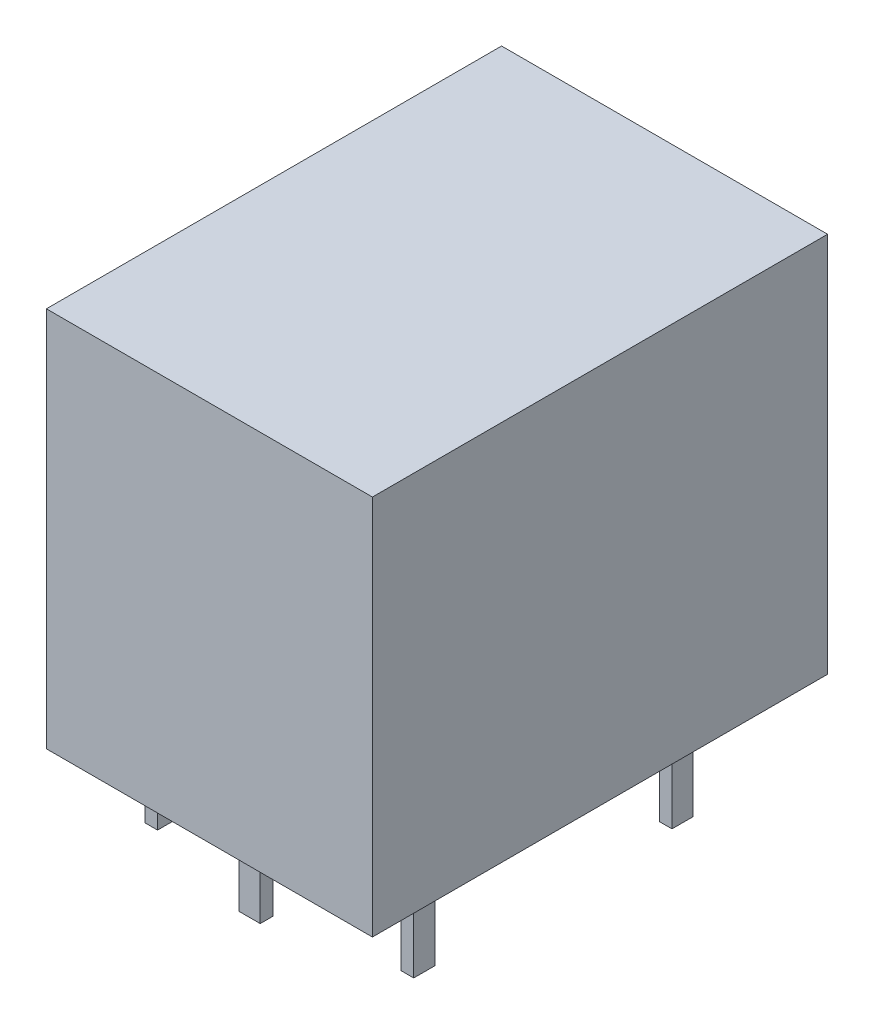
from build123d import *

# Parameters (mm, degrees)
SKETCH1_W             = 15.4
SKETCH1_H             = 21.5
BOSS_EXTRUDE1_DEPTH   = 18
SKETCH2_W             = 0.6
SKETCH2_H             = 1
BOSS_EXTRUDE2_DEPTH   = 4
BOSS_EXTRUDE2_2_DEPTH = 4
SKETCH2_W_2           = 1
SKETCH2_H_2           = 0.6
BOSS_EXTRUDE2_3_DEPTH = 4
BOSS_EXTRUDE2_4_DEPTH = 4
BOSS_EXTRUDE2_5_DEPTH = 4


with BuildPart() as part:
    # Sketch1 → Boss-Extrude1 (new body)
    with BuildSketch(Plane(origin=(0, 0, 0), x_dir=(1, 0, 0), z_dir=(0, 1, 0))):
        Rectangle(SKETCH1_W, SKETCH1_H)
    extrude(amount=BOSS_EXTRUDE1_DEPTH)


with BuildPart() as body_2:
    # Sketch2 → Boss-Extrude2 (new body)
    with BuildSketch(Plane.XZ):
        with Locations((-6.05, -5.25)):
            Rectangle(SKETCH2_W, SKETCH2_H)
    extrude(amount=BOSS_EXTRUDE2_DEPTH)


with BuildPart() as body_3:
    # Sketch2 → Boss-Extrude2 2 (new body)
    with BuildSketch(Plane.XZ):
        with Locations((-6.05, 6.95)):
            Rectangle(SKETCH2_W, SKETCH2_H)
    extrude(amount=BOSS_EXTRUDE2_2_DEPTH)


with BuildPart() as body_4:
    # Sketch2 → Boss-Extrude2 3 (new body)
    with BuildSketch(Plane.XZ):
        with Locations((0, 8.55)):
            Rectangle(SKETCH2_W_2, SKETCH2_H_2)
    extrude(amount=BOSS_EXTRUDE2_3_DEPTH)


with BuildPart() as body_5:
    # Sketch2 → Boss-Extrude2 4 (new body)
    with BuildSketch(Plane.XZ):
        with Locations((6.05, 6.95)):
            Rectangle(SKETCH2_W, SKETCH2_H)
    extrude(amount=BOSS_EXTRUDE2_4_DEPTH)


with BuildPart() as body_6:
    # Sketch2 → Boss-Extrude2 5 (new body)
    with BuildSketch(Plane.XZ):
        with Locations((6.05, -5.25)):
            Rectangle(SKETCH2_W, SKETCH2_H)
    extrude(amount=BOSS_EXTRUDE2_5_DEPTH)


solid = Compound([part.part, body_2.part, body_3.part, body_4.part, body_5.part, body_6.part])
